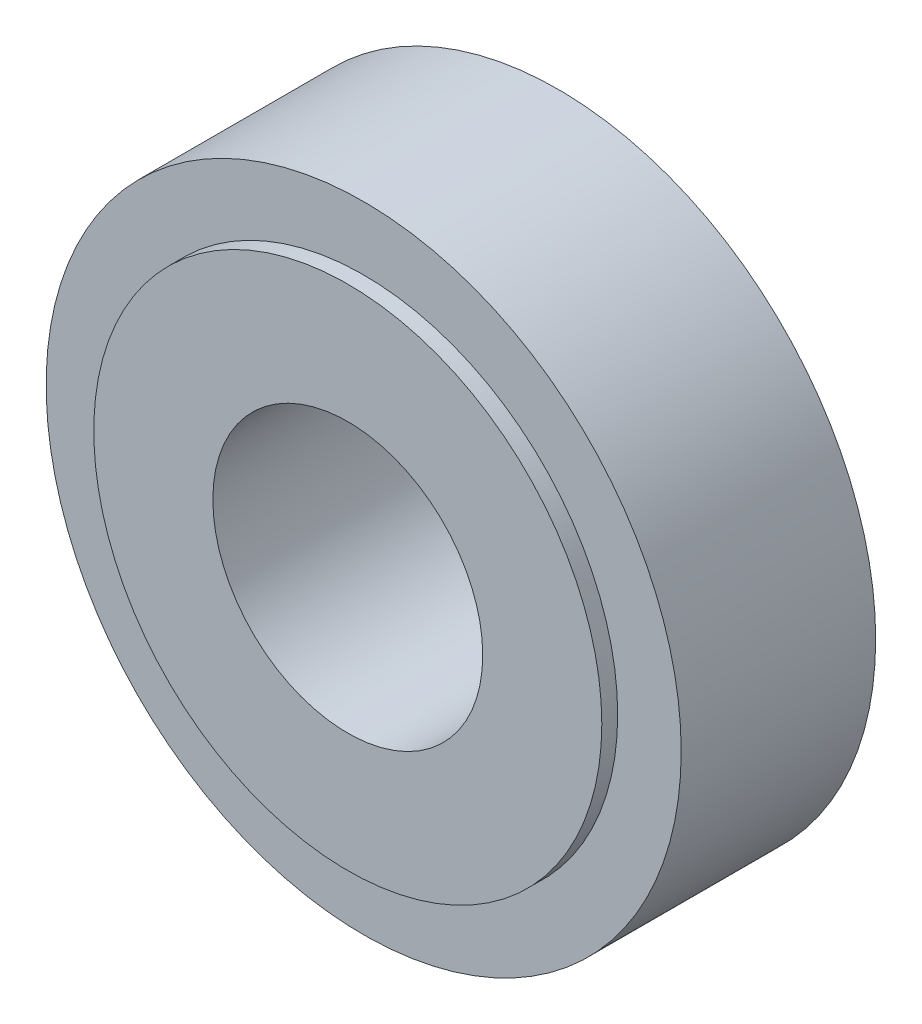
from build123d import *

# Parameters (mm, degrees)
ESQUISSE1_R             = 20
ESQUISSE1_R_2           = 8.5
BOSS_EXTRU_1_DEPTH      = 13.25
ESQUISSE2_R             = 17
ENL_V_MAT_EXTRU_1_DEPTH = 1
ESQUISSE3_OUTSIDE_W     = 53.62
ESQUISSE3_OUTSIDE_H     = 53.62
ESQUISSE3_OUTSIDE_R     = 16
ENL_V_MAT_EXTRU_2_DEPTH = 1


with BuildPart() as part:
    # Esquisse1 → Boss.-Extru.1 (new body)
    with BuildSketch(Plane.XY):
        Circle(ESQUISSE1_R)
        Circle(ESQUISSE1_R_2, mode=Mode.SUBTRACT)
    extrude(amount=BOSS_EXTRU_1_DEPTH)

    # Esquisse2 → Enlèv. mat.-Extru.1 (cut)
    with BuildSketch(Plane(origin=(0, 0, 0), x_dir=(-1, 0, 0), z_dir=(0, 0, -1))):
        Circle(ESQUISSE2_R)
    extrude(amount=-ENL_V_MAT_EXTRU_1_DEPTH, mode=Mode.SUBTRACT)

    # Esquisse3 outside → Enlèv. mat.-Extru.2 (cut)
    with BuildSketch(Plane.XY.offset(13.25)):
        Rectangle(ESQUISSE3_OUTSIDE_W, ESQUISSE3_OUTSIDE_H)
        Circle(ESQUISSE3_OUTSIDE_R, mode=Mode.SUBTRACT)
    extrude(amount=-ENL_V_MAT_EXTRU_2_DEPTH, mode=Mode.SUBTRACT)


solid = part.part
